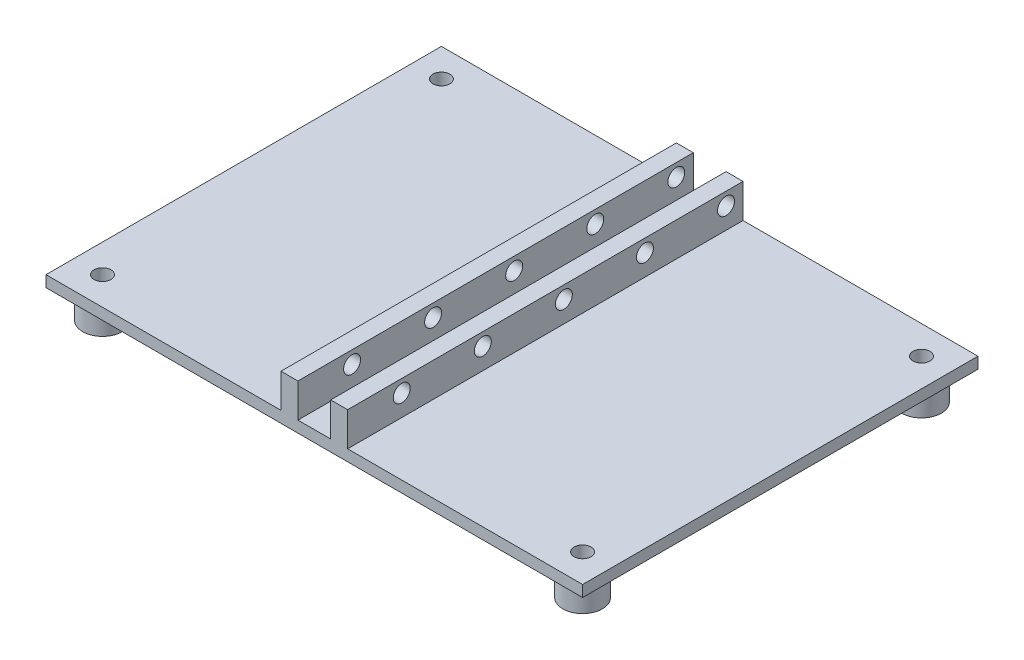
from build123d import *

# Parameters (mm, degrees)
SKETCH_1_W          = 95
SKETCH_1_H          = 70
SKETCH_1_R          = 1.5
EXTRUDE_1_DEPTH     = 2
SKETCH_2_W          = 3
SKETCH_2_H          = 70
EXTRUDE_2_DEPTH     = 6
SKETCH_3_R          = 1.5
CUT_EXTRUDE_1_DEPTH = 54.4
SKETCH_4_R          = 3.5
SKETCH_4_R_2        = 1.5
EXTRUDE_3_DEPTH     = 5


with BuildPart() as part:
    # 草图1 → 凸台-拉伸1 (new body)
    with BuildSketch(Plane(origin=(0, 0, 0), x_dir=(1, 0, 0), z_dir=(0, 1, 0))):
        Rectangle(SKETCH_1_W, SKETCH_1_H)
        with Locations((-42.5, 30)):
            Circle(SKETCH_1_R, mode=Mode.SUBTRACT)
        with Locations((42.5, 30)):
            Circle(SKETCH_1_R, mode=Mode.SUBTRACT)
        with Locations((-42.5, -30)):
            Circle(SKETCH_1_R, mode=Mode.SUBTRACT)
        with Locations((42.5, -30)):
            Circle(SKETCH_1_R, mode=Mode.SUBTRACT)
    extrude(amount=EXTRUDE_1_DEPTH)

    # 草图2 → 凸台-拉伸2 (add)
    with BuildSketch(Plane(origin=(0, 2, 0), x_dir=(1, 0, 0), z_dir=(0, 1, 0))):
        with Locations((-4.4, 0)):
            Rectangle(SKETCH_2_W, SKETCH_2_H)
        with Locations((4.4, 0)):
            Rectangle(SKETCH_2_W, SKETCH_2_H)
    extrude(amount=EXTRUDE_2_DEPTH)

    # 草图3 → 切除-拉伸1 (cut, through all)
    with BuildSketch(Plane.ZY.offset(5.9)):
        with Locations((-31.985850954, 5.75)):
            Circle(SKETCH_3_R)
        with Locations((-17.635850954, 5.75)):
            Circle(SKETCH_3_R)
        with Locations((-3.285850954, 5.75)):
            Circle(SKETCH_3_R)
        with Locations((11.064149046, 5.75)):
            Circle(SKETCH_3_R)
        with Locations((25.414149046, 5.75)):
            Circle(SKETCH_3_R)
    extrude(amount=-CUT_EXTRUDE_1_DEPTH, mode=Mode.SUBTRACT)

    # 草图4 → 凸台-拉伸3 (add)
    with BuildSketch(Plane.XZ):
        with Locations((-42.5, -30)):
            Circle(SKETCH_4_R)
        with Locations((-42.5, -30)):
            Circle(SKETCH_4_R_2, mode=Mode.SUBTRACT)
        with Locations((-42.5, 30)):
            Circle(SKETCH_4_R)
        with Locations((-42.5, 30)):
            Circle(SKETCH_4_R_2, mode=Mode.SUBTRACT)
        with Locations((42.5, 30)):
            Circle(SKETCH_4_R)
        with Locations((42.5, 30)):
            Circle(SKETCH_4_R_2, mode=Mode.SUBTRACT)
        with Locations((42.5, -30)):
            Circle(SKETCH_4_R)
        with Locations((42.5, -30)):
            Circle(SKETCH_4_R_2, mode=Mode.SUBTRACT)
    extrude(amount=EXTRUDE_3_DEPTH)


solid = part.part
